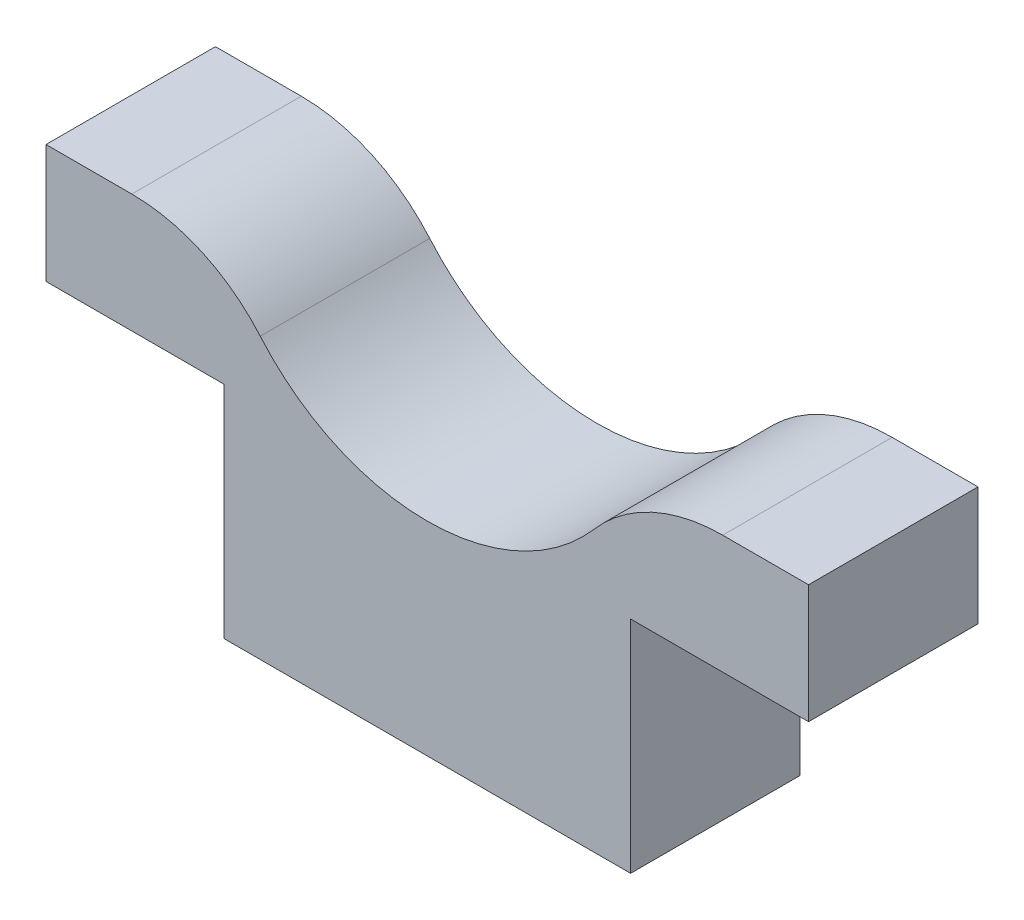
from build123d import *

# Parameters (mm, degrees)
SKETCH1_W           = 24
SKETCH1_H           = 13
BOSS_EXTRUDE1_DEPTH = 10
CUT_EXTRUDE2_DEPTH  = 11
FILLET1_R           = 10


with BuildPart() as part:
    # Sketch1 → Boss-Extrude1 (new body)
    with BuildSketch(Plane.XY):
        with Locations((12, 6.5)):
            Rectangle(SKETCH1_W, SKETCH1_H)
        Polygon((24, 13), (34.5, 13), (34.5, 20), (-10.5, 20), (-10.5, 13), (0, 13), align=None)
    extrude(amount=BOSS_EXTRUDE1_DEPTH)

    # Sketch2 → Cut-Extrude2 (cut, through all)
    with BuildSketch(Plane(origin=(0, 0, 0), x_dir=(-1, 0, 0), z_dir=(0, 0, -1))):
        with BuildLine():
            Line((0, 20), (-24, 20))
            ThreePointArc((-24, 20), (-12, 12), (0, 20))
        make_face()
    extrude(amount=-CUT_EXTRUDE2_DEPTH, mode=Mode.SUBTRACT)

    # Fillet1
    fillet1_edges = [part.edges().sort_by_distance(p)[0] for p in [
        (0, 20, 5),
        (24, 20, 5),
    ]]
    fillet(fillet1_edges, radius=FILLET1_R)


solid = part.part
